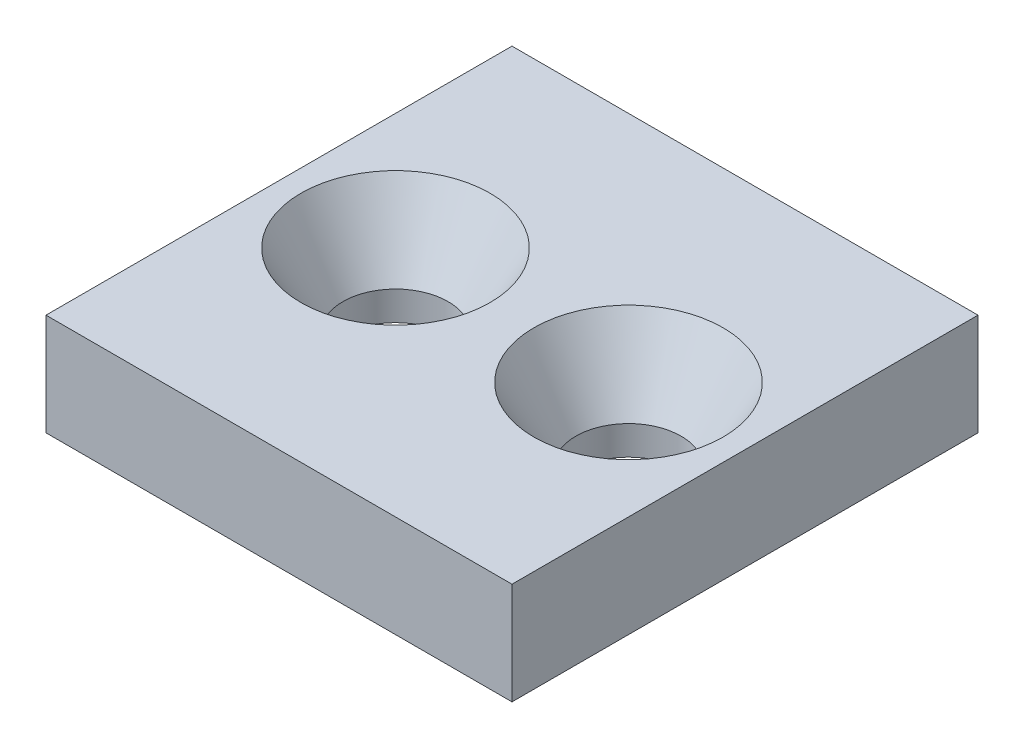
from build123d import *

# Parameters (mm, degrees)
SKETCH1_W           = 32
SKETCH1_H           = 32
BOSS_EXTRUDE1_DEPTH = 3.5


with BuildPart() as part:
    # Sketch1 → Boss-Extrude1 (new body, symmetric)
    with BuildSketch(Plane(origin=(0, 0, 0), x_dir=(1, 0, 0), z_dir=(0, 1, 0))):
        Rectangle(SKETCH1_W, SKETCH1_H)
    extrude(amount=BOSS_EXTRUDE1_DEPTH, both=True)

    # Sketch2 → Cut-Revolve1 (revolve, cut)
    with BuildSketch(Plane.XY):
        Polygon((8, 3.5), (14.5, 3.5), (11.613248654, -1.5), (11.613248654, -3.5), (8, -3.5), align=None)
    cut_revolve1 = revolve(axis=Axis((8, 3.5, 0), (0, -1, 0)), mode=Mode.SUBTRACT)

    # Mirror1: Cut-Revolve1 across plane
    add(cut_revolve1.mirror(Plane(origin=(0, 0, 0), x_dir=(0, 0, 1), z_dir=(1, 0, 0))), mode=Mode.SUBTRACT)


solid = part.part
